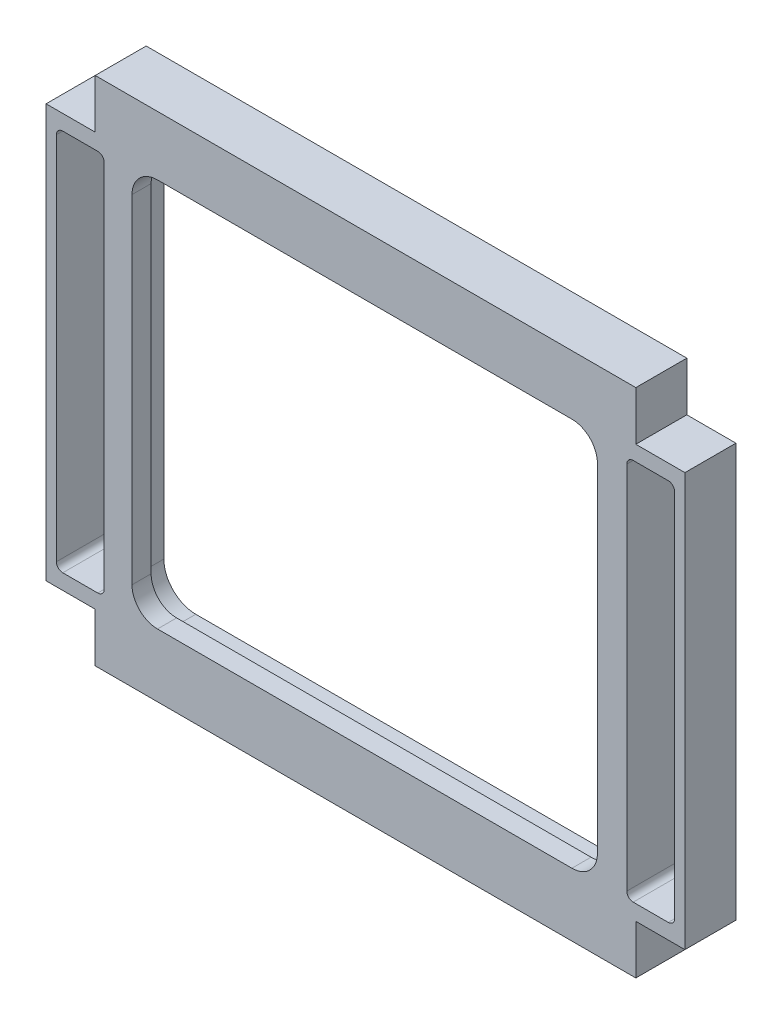
from build123d import *

# Parameters (mm, degrees)
BOSS_EXTRU_1_DEPTH      = 5
BOSS_EXTRU_2_DEPTH      = 3
ENL_V_MAT_EXTRU_9_DEPTH = 10
ENL_V_MAT_EXTRU_4_DEPTH = 9


with BuildPart() as part:
    # Esquisse1 → Boss.-Extru.1 (new body)
    with BuildSketch(Plane.XY):
        Polygon((-40.258600608, 39.883341456), (44.541399392, 39.883341456), (44.541399392, 32.183341456), (52.241399392, 32.183341456), (52.241399392, -32.616658544), (44.541399392, -32.616658544), (44.541399392, -40.316658544), (-40.258600608, -40.316658544), (-40.258600608, -32.616658544), (-47.958600608, -32.616658544), (-47.958600608, 32.183341456), (-40.258600608, 32.183341456), align=None)
        with BuildLine():
            Line((-32.483600608, 33.583341456), (36.516399392, 33.583341456))
            ThreePointArc((36.516399392, 33.583341456), (40.051933298, 32.118875362), (41.516399392, 28.583341456))
            Line((41.516399392, 28.583341456), (41.516399392, -28.416658544))
            ThreePointArc((41.516399392, -28.416658544), (40.051933298, -31.952192449), (36.516399392, -33.416658544))
            Line((36.516399392, -33.416658544), (-32.483600608, -33.416658544))
            ThreePointArc((-32.483600608, -33.416658544), (-36.019134514, -31.952192449), (-37.483600608, -28.416658544))
            Line((-37.483600608, -28.416658544), (-37.483600608, 28.583341456))
            ThreePointArc((-37.483600608, 28.583341456), (-36.019134514, 32.118875362), (-32.483600608, 33.583341456))
        make_face(mode=Mode.SUBTRACT)
    extrude(amount=BOSS_EXTRU_1_DEPTH)

    # Esquisse2 → Boss.-Extru.2 (add)
    with BuildSketch(Plane.XY.offset(5)):
        Polygon((-47.958600608, 32.183341456), (-40.258600608, 32.183341456), (-40.258600608, 39.883341456), (44.541399392, 39.883341456), (44.541399392, 32.183341456), (52.241399392, 32.183341456), (52.241399392, -32.616658544), (44.541399392, -32.616658544), (44.541399392, -40.316658544), (-40.258600608, -40.316658544), (-40.258600608, -32.616658544), (-47.958600608, -32.616658544), align=None)
    extrude(amount=BOSS_EXTRU_2_DEPTH)

    # Esquisse8 → Enlèv. mat.-Extru.9 (cut)
    with BuildSketch(Plane(origin=(0, 0, 5), x_dir=(-1, 0, 0), z_dir=(0, 0, -1))):
        with BuildLine():
            Line((-34.516399392, 30.583341456), (30.483600608, 30.583341456))
            ThreePointArc((30.483600608, 30.583341456), (33.312027733, 29.411768581), (34.483600608, 26.583341456))
            Line((34.483600608, 26.583341456), (34.483600608, -26.416658544))
            ThreePointArc((34.483600608, -26.416658544), (33.312027733, -29.245085668), (30.483600608, -30.416658544))
            Line((30.483600608, -30.416658544), (-34.516399392, -30.416658544))
            ThreePointArc((-34.516399392, -30.416658544), (-37.344826516, -29.245085668), (-38.516399392, -26.416658544))
            Line((-38.516399392, -26.416658544), (-38.516399392, 26.583341456))
            ThreePointArc((-38.516399392, 26.583341456), (-37.344826516, 29.411768581), (-34.516399392, 30.583341456))
        make_face()
    extrude(amount=-ENL_V_MAT_EXTRU_9_DEPTH, mode=Mode.SUBTRACT)

    # Esquisse6 → Enlèv. mat.-Extru.4 (cut, through all)
    with BuildSketch(Plane(origin=(0, 0, 0), x_dir=(-1, 0, 0), z_dir=(0, 0, -1))):
        with BuildLine():
            Line((-49.628899392, 29.783341456), (-44.128899392, 29.783341456))
            ThreePointArc((-44.128899392, 29.783341456), (-43.421792611, 29.490448238), (-43.128899392, 28.783341456))
            Line((-43.128899392, 28.783341456), (-43.128899392, -29.216658544))
            ThreePointArc((-43.128899392, -29.216658544), (-43.421792611, -29.923765325), (-44.128899392, -30.216658544))
            Line((-44.128899392, -30.216658544), (-49.628899392, -30.216658544))
            ThreePointArc((-49.628899392, -30.216658544), (-50.336006173, -29.923765325), (-50.628899392, -29.216658544))
            Line((-50.628899392, -29.216658544), (-50.628899392, 28.783341456))
            ThreePointArc((-50.628899392, 28.783341456), (-50.336006173, 29.490448238), (-49.628899392, 29.783341456))
        make_face()
        with BuildLine():
            Line((45.346100608, -30.216658544), (39.846100608, -30.216658544))
            ThreePointArc((39.846100608, -30.216658544), (39.138993827, -29.923765325), (38.846100608, -29.216658544))
            Line((38.846100608, -29.216658544), (38.846100608, 28.783341456))
            ThreePointArc((38.846100608, 28.783341456), (39.138993827, 29.490448238), (39.846100608, 29.783341456))
            Line((39.846100608, 29.783341456), (45.346100608, 29.783341456))
            ThreePointArc((45.346100608, 29.783341456), (46.053207389, 29.490448238), (46.346100608, 28.783341456))
            Line((46.346100608, 28.783341456), (46.346100608, -29.216658544))
            ThreePointArc((46.346100608, -29.216658544), (46.053207389, -29.923765325), (45.346100608, -30.216658544))
        make_face()
    extrude(amount=-ENL_V_MAT_EXTRU_4_DEPTH, mode=Mode.SUBTRACT)


solid = part.part
